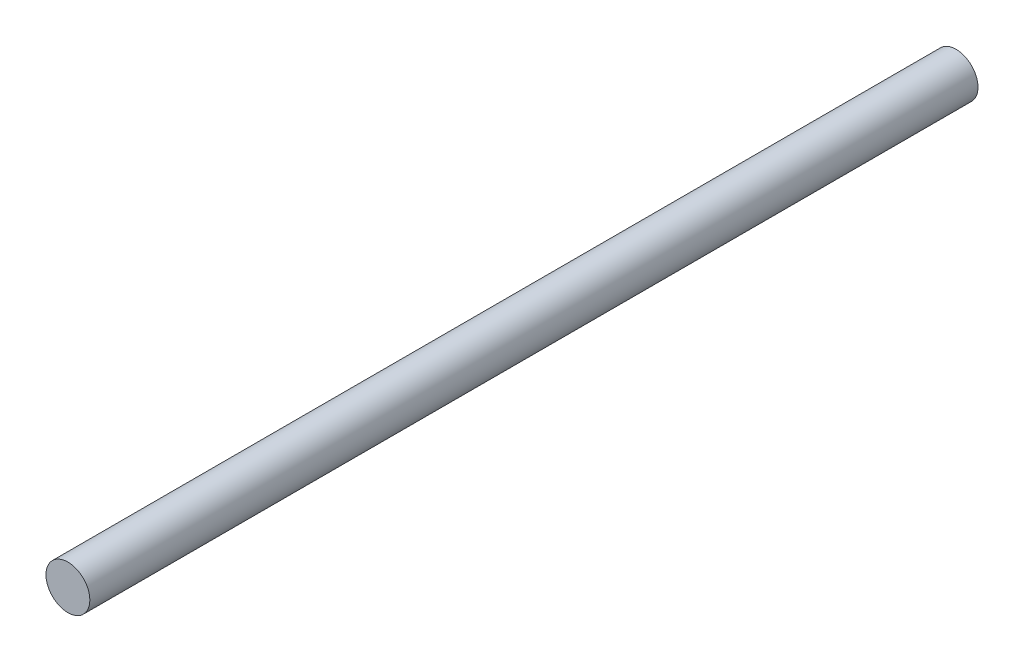
from build123d import *

# Parameters (mm, degrees)
SKETCH1_R           = 11.1125
BOSS_EXTRUDE1_DEPTH = 450


with BuildPart() as part:
    # Sketch1 → Boss-Extrude1 (new body)
    with BuildSketch(Plane.XY):
        Circle(SKETCH1_R)
    extrude(amount=BOSS_EXTRUDE1_DEPTH)


solid = part.part
